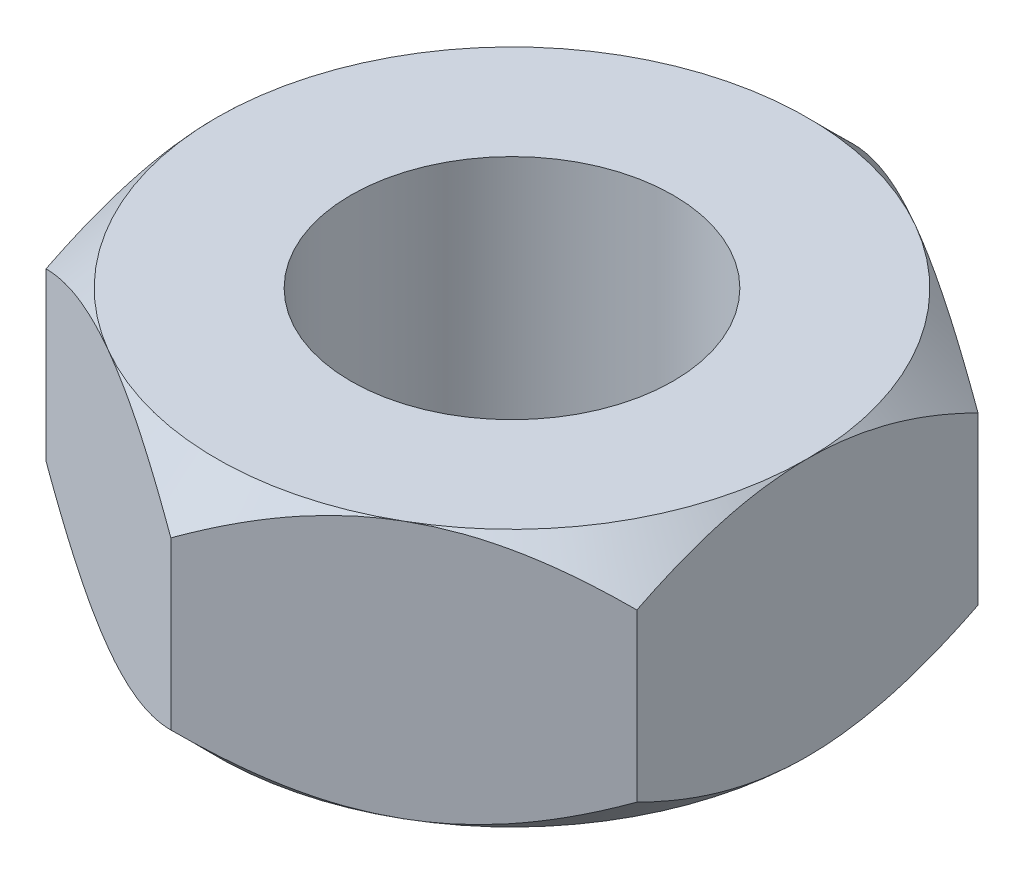
from build123d import *

# Parameters (mm, degrees)
SKETCH1_R           = 1.5
BOSS_EXTRUDE1_DEPTH = 2.4
SKETCH2_OUTSIDE_W   = 16.048
SKETCH2_OUTSIDE_H   = 16.898
SKETCH2_OUTSIDE_R   = 2.75
CUT_EXTRUDE1_DEPTH  = 3.4
CUT_EXTRUDE1_TAPER  = 45
SKETCH3_OUTSIDE_W   = 16.048
SKETCH3_OUTSIDE_H   = 16.898
SKETCH3_OUTSIDE_R   = 2.75
CUT_EXTRUDE2_DEPTH  = 3.4
CUT_EXTRUDE2_TAPER  = 45


with BuildPart() as part:
    # Sketch1 → Boss-Extrude1 (new body)
    with BuildSketch(Plane(origin=(0, 0, 0), x_dir=(1, 0, 0), z_dir=(0, 1, 0))):
        Polygon((0, 3.175426481), (-2.75, 1.58771324), (-2.75, -1.58771324), (0, -3.175426481), (2.75, -1.58771324), (2.75, 1.58771324), align=None)
        Circle(SKETCH1_R, mode=Mode.SUBTRACT)
    extrude(amount=BOSS_EXTRUDE1_DEPTH)

    # Sketch2 outside → Cut-Extrude1 (cut, through all)
    with BuildSketch(Plane(origin=(0, 2.4, 0), x_dir=(1, 0, 0), z_dir=(0, 1, 0))):
        Rectangle(SKETCH2_OUTSIDE_W, SKETCH2_OUTSIDE_H)
        Circle(SKETCH2_OUTSIDE_R, mode=Mode.SUBTRACT)
    extrude(amount=-CUT_EXTRUDE1_DEPTH, taper=CUT_EXTRUDE1_TAPER, mode=Mode.SUBTRACT)

    # Sketch3 outside → Cut-Extrude2 (cut, through all)
    with BuildSketch(Plane.XZ):
        Rectangle(SKETCH3_OUTSIDE_W, SKETCH3_OUTSIDE_H)
        Circle(SKETCH3_OUTSIDE_R, mode=Mode.SUBTRACT)
    extrude(amount=-CUT_EXTRUDE2_DEPTH, taper=CUT_EXTRUDE2_TAPER, mode=Mode.SUBTRACT)


solid = part.part
